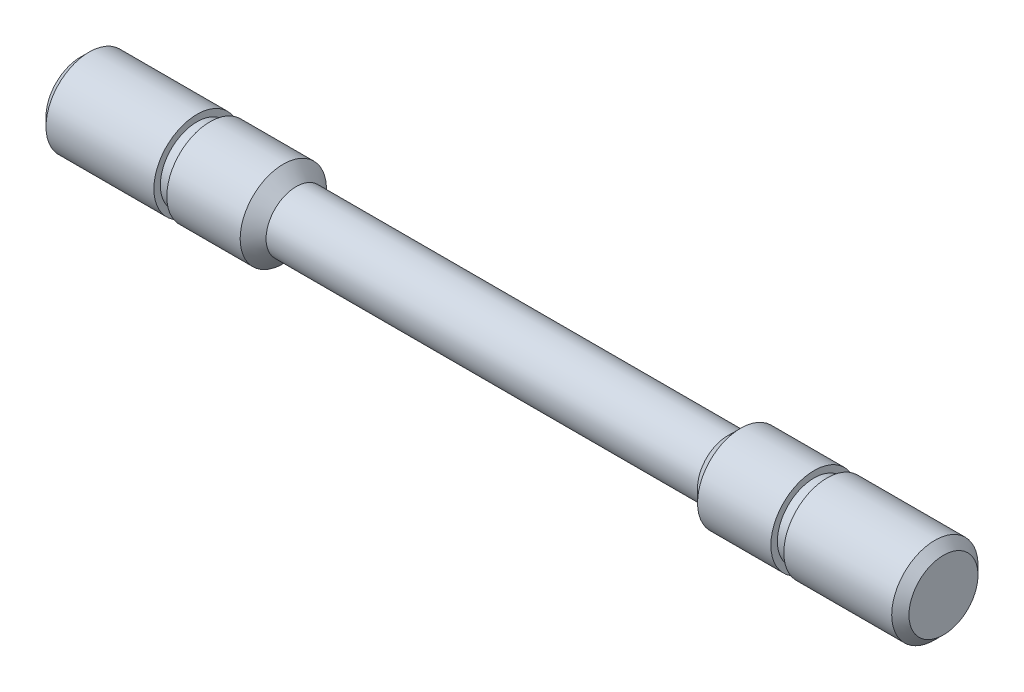
from build123d import *


with BuildPart() as part:
    # Esquisse1 → Révolution1 (revolve)
    with BuildSketch(Plane.XY):
        Polygon((0, 0), (0, 3.5), (-25, 3.5), (-26.5, 5), (-35, 5), (-35, 4.25), (-36.5, 4.25), (-36.5, 5), (-49, 5), (-50, 4), (-50, 0), align=None)
    r_volution1 = revolve(axis=Axis((-50, 0, 0), (1, 0, 0)))

    # Symétrie1: Révolution1 across Right Plane
    add(r_volution1.mirror(Plane(origin=(0, 0, 0), x_dir=(0, 0, -1), z_dir=(1, 0, 0))))


solid = part.part
